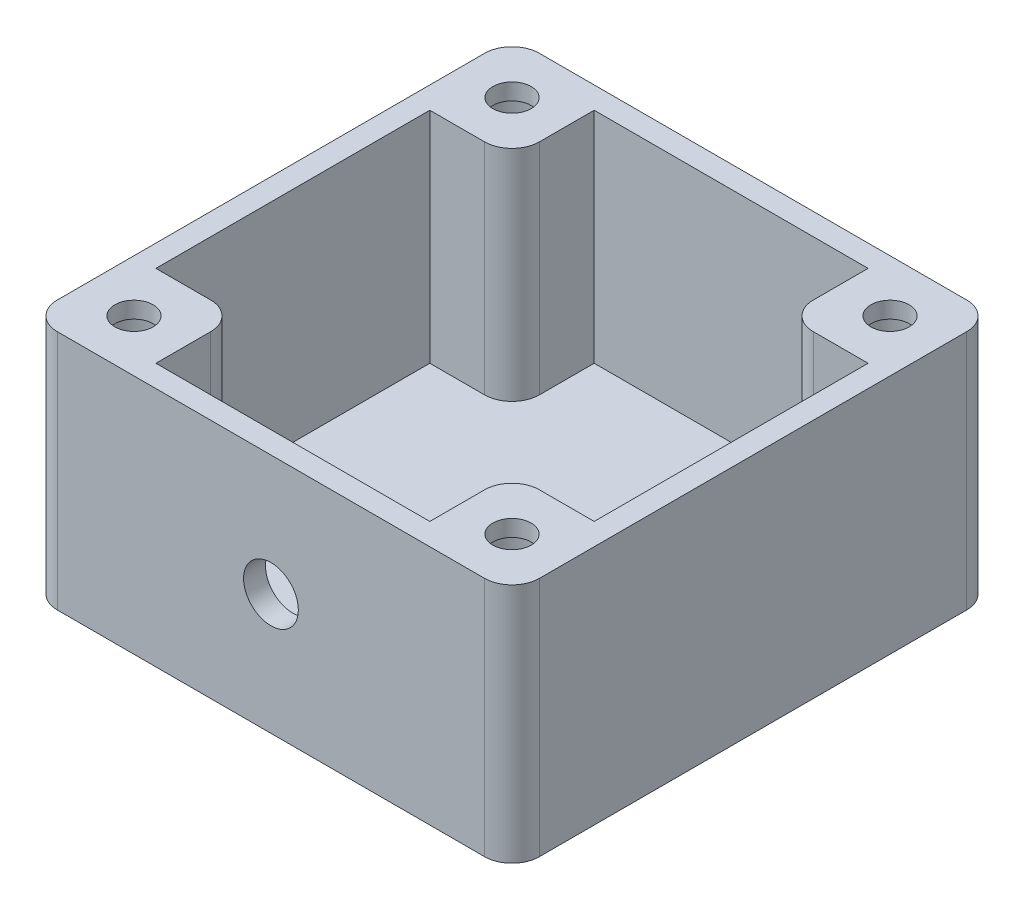
from build123d import *

# Parameters (mm, degrees)
SKETCH1_W           = 44
SKETCH1_H           = 44
SKETCH1_W_2         = 25
SKETCH1_H_2         = 40
BOSS_EXTRUDE4_DEPTH = 20
SKETCH4_W           = 44
SKETCH4_H           = 44
BOSS_EXTRUDE5_DEPTH = 2
SKETCH5_R           = 3.45
CUT_EXTRUDE2_DEPTH  = 2
SKETCH6_R           = 1.75
CUT_EXTRUDE3_DEPTH  = 23
SKETCH7_R           = 3.25
CUT_EXTRUDE4_DEPTH  = 20.5
SKETCH10_W          = 7.5
SKETCH10_H          = 25
CUT_EXTRUDE5_DEPTH  = 20
CUT_EXTRUDE6_REACH  = 46
SKETCH11_R          = 2.5
FILLET1_R           = 2.5


with BuildPart() as part:
    # Sketch1 → Boss-Extrude4 (new body)
    with BuildSketch(Plane(origin=(0, 0, 0), x_dir=(1, 0, 0), z_dir=(0, 1, 0))):
        Rectangle(SKETCH1_W, SKETCH1_H)
        Rectangle(SKETCH1_W_2, SKETCH1_H_2, mode=Mode.SUBTRACT)
    extrude(amount=BOSS_EXTRUDE4_DEPTH)

    # Sketch4 → Boss-Extrude5 (add)
    with BuildSketch(Plane.XZ):
        Rectangle(SKETCH4_W, SKETCH4_H)
    extrude(amount=BOSS_EXTRUDE5_DEPTH)

    # Sketch5 → Cut-Extrude2 (cut)
    with BuildSketch(Plane(origin=(0, 0, 0), x_dir=(1, 0, 0), z_dir=(0, 1, 0))):
        Circle(SKETCH5_R)
        with BuildLine():
            Line((-4.388708392, -8.222009531), (-1.963213799, -9.153124979))
            ThreePointArc((-1.963213799, -9.153124979), (-2.369591464, -6.58702732), (-4.388708392, -8.222009531))
        make_face()
    extrude(amount=-CUT_EXTRUDE2_DEPTH, mode=Mode.SUBTRACT)

    # Sketch6 → Cut-Extrude3 (cut, through all)
    with BuildSketch(Plane(origin=(0, 20, 0), x_dir=(1, 0, 0), z_dir=(0, 1, 0))):
        with Locations((-17.25, 17.25)):
            Circle(SKETCH6_R)
        with Locations((-17.25, -17.25)):
            Circle(SKETCH6_R)
    cut_extrude3 = extrude(amount=-CUT_EXTRUDE3_DEPTH, mode=Mode.SUBTRACT)

    # Mirror1: Cut-Extrude3 across plane
    add(cut_extrude3.mirror(Plane(origin=(0, 0, 0), x_dir=(0, 0, 1), z_dir=(1, 0, 0))), mode=Mode.SUBTRACT)

    # Sketch7 → Cut-Extrude4 (cut)
    with BuildSketch(Plane.XZ.offset(2)):
        with Locations((-17.25, 17.25)):
            Circle(SKETCH7_R)
        with Locations((17.25, 17.25)):
            Circle(SKETCH7_R)
        with Locations((17.25, -17.25)):
            Circle(SKETCH7_R)
        with Locations((-17.25, -17.25)):
            Circle(SKETCH7_R)
    extrude(amount=-CUT_EXTRUDE4_DEPTH, mode=Mode.SUBTRACT)

    # Sketch10 → Cut-Extrude5 (cut)
    with BuildSketch(Plane(origin=(0, 20, 0), x_dir=(1, 0, 0), z_dir=(0, 1, 0))):
        with Locations((-16.25, 0)):
            Rectangle(SKETCH10_W, SKETCH10_H)
    cut_extrude5 = extrude(amount=-CUT_EXTRUDE5_DEPTH, mode=Mode.SUBTRACT)

    # Mirror2: Cut-Extrude5 across plane
    add(cut_extrude5.mirror(Plane(origin=(0, 0, 0), x_dir=(0, 0, 1), z_dir=(1, 0, 0))), mode=Mode.SUBTRACT)

    # Sketch11 → Cut-Extrude6 (cut, up to next)
    with BuildSketch(Plane.XY.offset(22), mode=Mode.PRIVATE) as cut_extrude6_sk1:
        with Locations((0, 9)):
            Circle(SKETCH11_R)
    cut_extrude6_tool1 = extrude(cut_extrude6_sk1.sketch, amount=-CUT_EXTRUDE6_REACH, mode=Mode.PRIVATE) & part.part
    add(cut_extrude6_tool1.solids().sort_by_distance((0, 9, 22))[0], mode=Mode.SUBTRACT)

    # Fillet1
    fillet1_edges = [part.edges().sort_by_distance(p)[0] for p in [
        (-12.5, 10, 12.5),
        (-12.5, 10, -12.5),
        (12.5, 10, 12.5),
        (12.5, 10, -12.5),
        (22, 9, 22),
        (-22, 9, 22),
        (-22, 9, -22),
        (22, 9, -22),
    ]]
    fillet(fillet1_edges, radius=FILLET1_R)


solid = part.part
